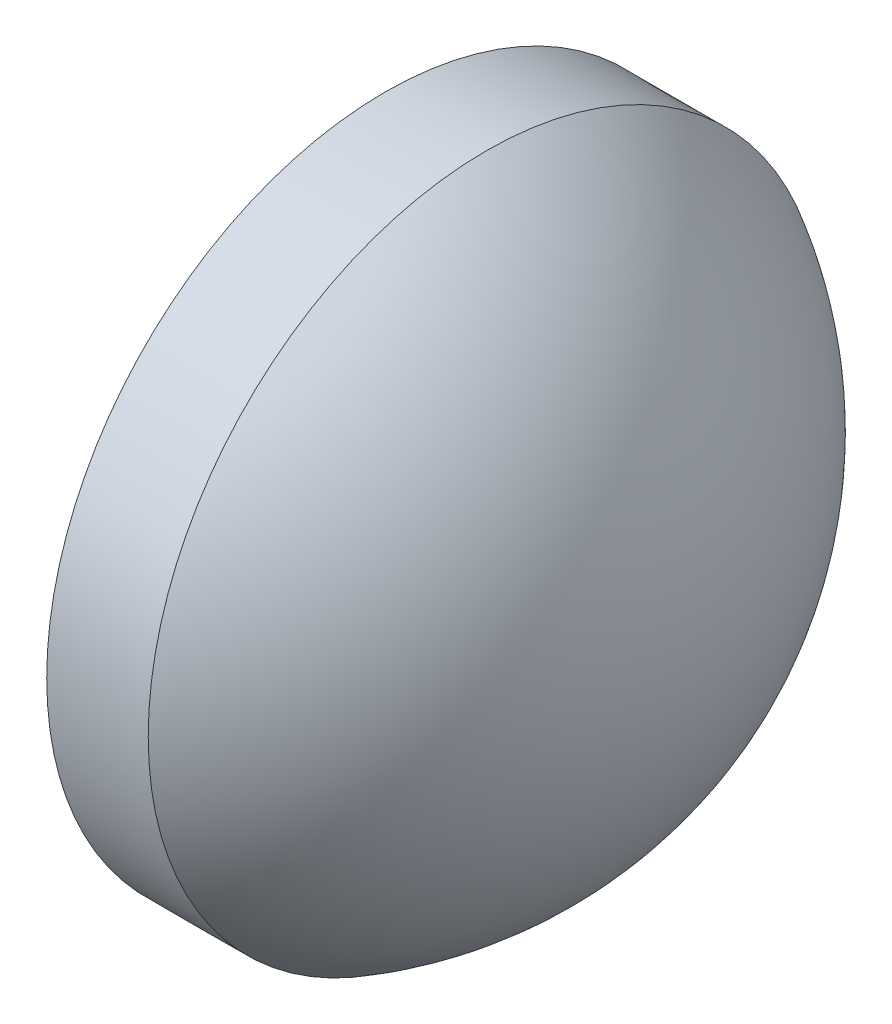
from build123d import *


with BuildPart() as part:
    # 草图2 → 旋转1 (revolve)
    with BuildSketch(Plane.XY, mode=Mode.PRIVATE) as revolve_1_sk:
        with BuildLine():
            Line((22.767377978, 18.064850241), (24.267377978, 18.064850241))
            ThreePointArc((24.267377978, 18.064850241), (26.410783507, 15.962702525), (27.197377954, 13.065379372))
            Line((27.197377954, 13.065379372), (22.767377978, 13.064850241))
            Line((22.767377978, 13.064850241), (22.767377978, 18.064850241))
        make_face()
    revolve(revolve_1_sk.sketch.rotate(Axis((22.254439213, 13.064788975, 0), (0.999999993, 0.000119443, 0)), 180), axis=Axis((22.254439213, 13.064788975, 0), (0.999999993, 0.000119443, 0)))  # turned: the seam where the file's is


solid = part.part
